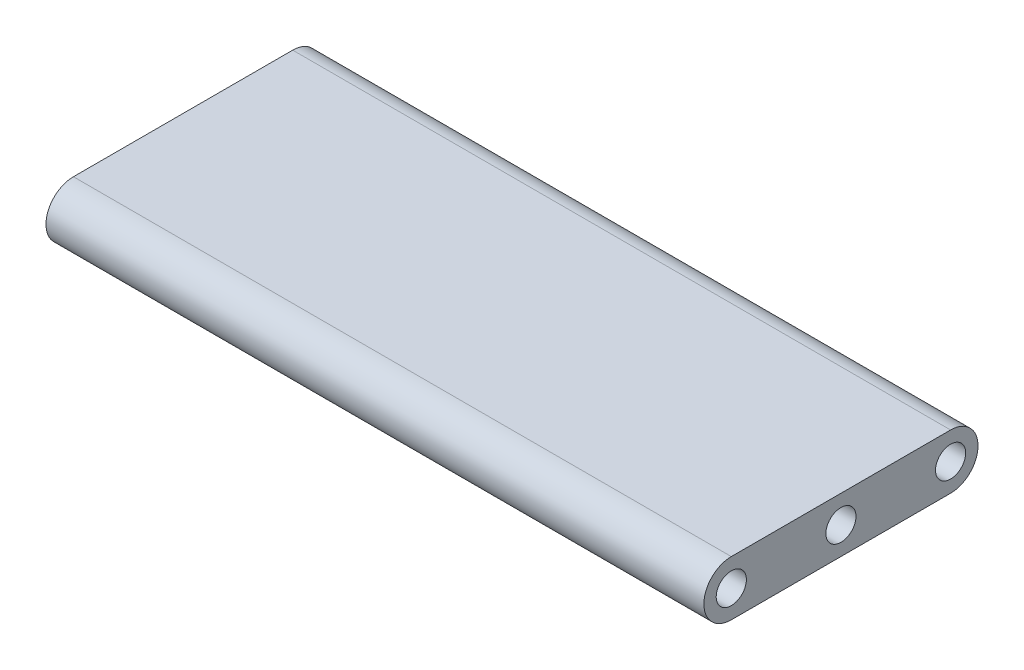
from build123d import *

# Parameters (mm, degrees)
SKETCH1_R           = 3.4925
BOSS_EXTRUDE1_DEPTH = 76.2


with BuildPart() as part:
    # Sketch1 → Boss-Extrude1 (new body, symmetric)
    with BuildSketch(Plane(origin=(0, 0, 0), x_dir=(0, 0, -1), z_dir=(1, 0, 0))):
        with BuildLine():
            Line((-25.4, -6.35), (25.4, -6.35))
            ThreePointArc((25.4, -6.35), (31.75, 0), (25.4, 6.35))
            Line((25.4, 6.35), (-25.4, 6.35))
            ThreePointArc((-25.4, 6.35), (-31.75, 0), (-25.4, -6.35))
        make_face()
        with Locations((-25.4, 0)):
            Circle(SKETCH1_R, mode=Mode.SUBTRACT)
        with Locations((25.4, 0)):
            Circle(SKETCH1_R, mode=Mode.SUBTRACT)
        Circle(SKETCH1_R, mode=Mode.SUBTRACT)
    extrude(amount=BOSS_EXTRUDE1_DEPTH, both=True)


solid = part.part
